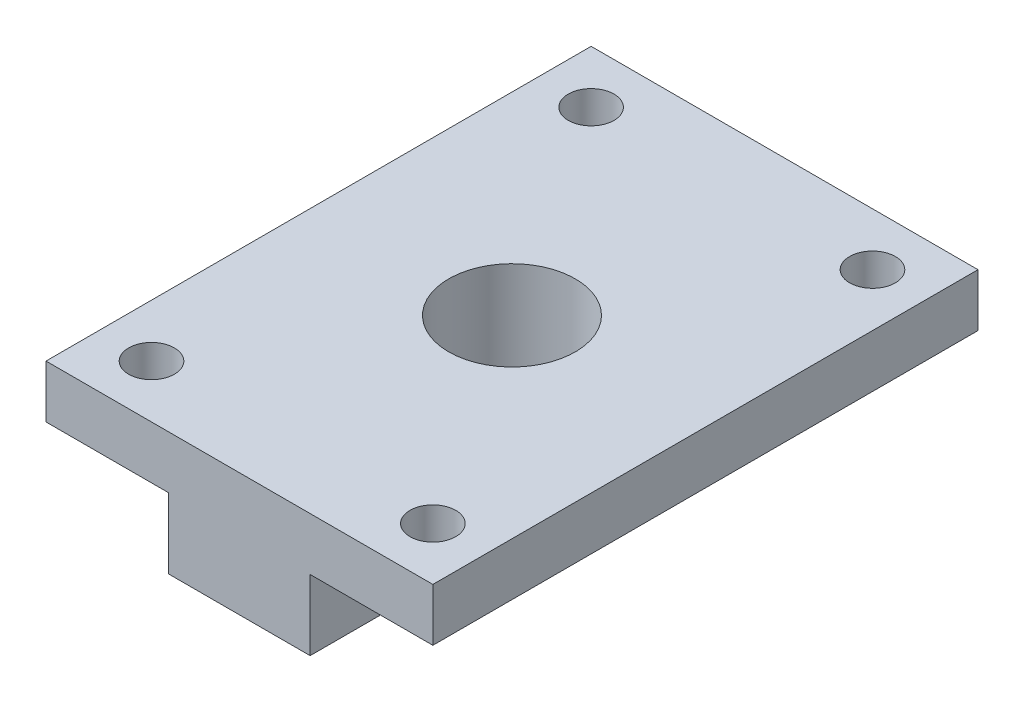
from build123d import *

# Parameters (mm, degrees)
SKETCH1_W           = 22
SKETCH1_H           = 31
SKETCH1_R           = 1.3
BOSS_EXTRUDE1_DEPTH = 7
SKETCH2_R           = 3.6
CUT_EXTRUDE1_DEPTH  = 10
SKETCH4_W           = 6.98
SKETCH4_H           = 31
CUT_EXTRUDE2_DEPTH  = 4


with BuildPart() as part:
    # Sketch1 → Boss-Extrude1 (new body)
    with BuildSketch(Plane(origin=(0, 0, 0), x_dir=(1, 0, 0), z_dir=(0, 1, 0))):
        Rectangle(SKETCH1_W, SKETCH1_H)
        with Locations((-8, 12.5)):
            Circle(SKETCH1_R, mode=Mode.SUBTRACT)
        with Locations((8, 12.5)):
            Circle(SKETCH1_R, mode=Mode.SUBTRACT)
        with Locations((-8, -12.5)):
            Circle(SKETCH1_R, mode=Mode.SUBTRACT)
        with Locations((8, -12.5)):
            Circle(SKETCH1_R, mode=Mode.SUBTRACT)
    extrude(amount=BOSS_EXTRUDE1_DEPTH)

    # Sketch2 → Cut-Extrude1 (cut)
    with BuildSketch(Plane(origin=(0, 7, 0), x_dir=(1, 0, 0), z_dir=(0, 1, 0))):
        Circle(SKETCH2_R)
    extrude(amount=-CUT_EXTRUDE1_DEPTH, mode=Mode.SUBTRACT)

    # Sketch4 → Cut-Extrude2 (cut)
    with BuildSketch(Plane.XZ):
        with Locations((7.51, 0)):
            Rectangle(SKETCH4_W, SKETCH4_H)
        with Locations((-7.51, 0)):
            Rectangle(SKETCH4_W, SKETCH4_H)
    extrude(amount=-CUT_EXTRUDE2_DEPTH, mode=Mode.SUBTRACT)


solid = part.part
